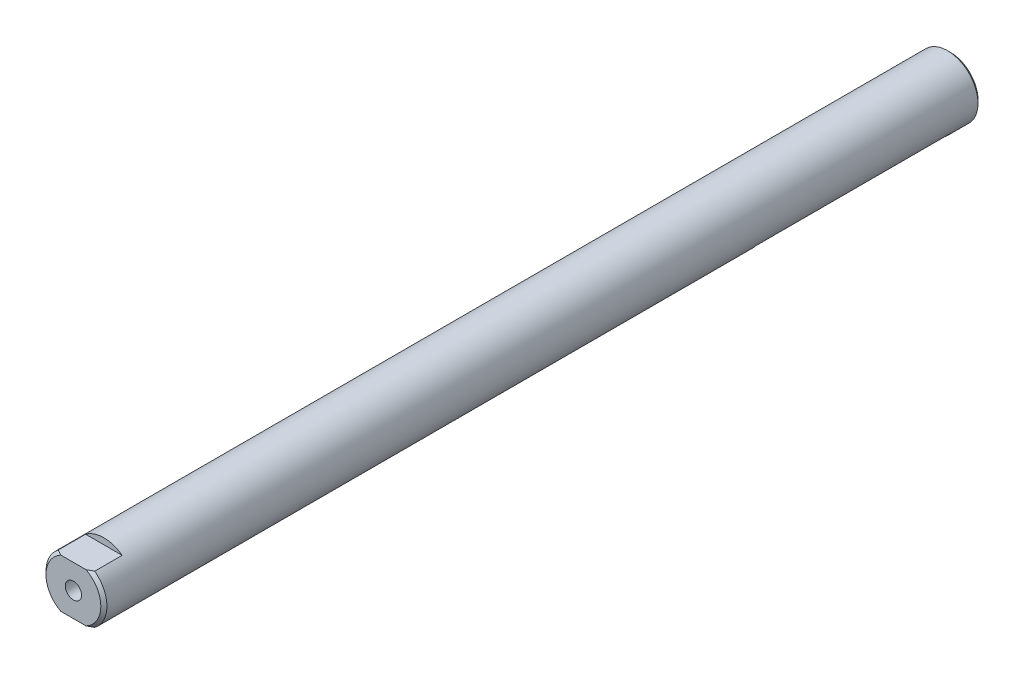
from build123d import *

# Parameters (mm, degrees)
SKETCH1_R                  = 15.875
BOSS_EXTRUDE1_DEPTH        = 228.6
SKETCH2_W                  = 50.8
SKETCH2_H                  = 101.981
CUT_EXTRUDE2_DEPTH         = 9.525
CHAMFER1_SIZE              = 1.5875
SKETCH3_W                  = 19.05
SKETCH3_H                  = 10.048588851
SKETCH3_H_2                = 8.582335087
CUT_EXTRUDE3_DEPTH         = 15.875
M10X1_5_TAPPED_HOLE1_D     = 8.5
M10X1_5_TAPPED_HOLE1_DEPTH = 27.686
M10X1_5_TAPPED_HOLE1_TIP   = 2.553657631


with BuildPart() as part:
    # Sketch1 → Boss-Extrude1 (new body, symmetric)
    with BuildSketch(Plane.XY):
        Circle(SKETCH1_R)
    extrude(amount=BOSS_EXTRUDE1_DEPTH, both=True)

    # Sketch2 → Cut-Extrude2 (cut)
    with BuildSketch(Plane(origin=(0, -19.05, 0), x_dir=(1, 0, 0), z_dir=(0, 1, 0))):
        with Locations((0, 165.1635)):
            Rectangle(SKETCH2_W, SKETCH2_H)
    extrude(amount=CUT_EXTRUDE2_DEPTH, mode=Mode.SUBTRACT)

    # Chamfer1
    chamfer1_edges = [part.edges().sort_by_distance(p)[0] for p in [
        (-15.875, 0, -228.6),
        (-15.875, 0, 228.6),
    ]]
    chamfer(chamfer1_edges, length=CHAMFER1_SIZE)

    # Sketch3 → Cut-Extrude3 (cut)
    with BuildSketch(Plane.XY.offset(228.6)):
        with Locations((0, 17.724294426)):
            Rectangle(SKETCH3_W, SKETCH3_H)
        with Locations((0, -16.991167544)):
            Rectangle(SKETCH3_W, SKETCH3_H_2)
    extrude(amount=-CUT_EXTRUDE3_DEPTH, mode=Mode.SUBTRACT)

    # M10x1.5 Tapped Hole1
    with Locations(Plane.XY.offset(228.6)):
        with Locations((0, 0)):
            Hole(M10X1_5_TAPPED_HOLE1_D / 2, depth=M10X1_5_TAPPED_HOLE1_DEPTH)
            with Locations((0, 0, -(M10X1_5_TAPPED_HOLE1_DEPTH + M10X1_5_TAPPED_HOLE1_TIP / 2))):  # 118° drill point
                Cone(0, M10X1_5_TAPPED_HOLE1_D / 2, M10X1_5_TAPPED_HOLE1_TIP, mode=Mode.SUBTRACT)


solid = part.part
